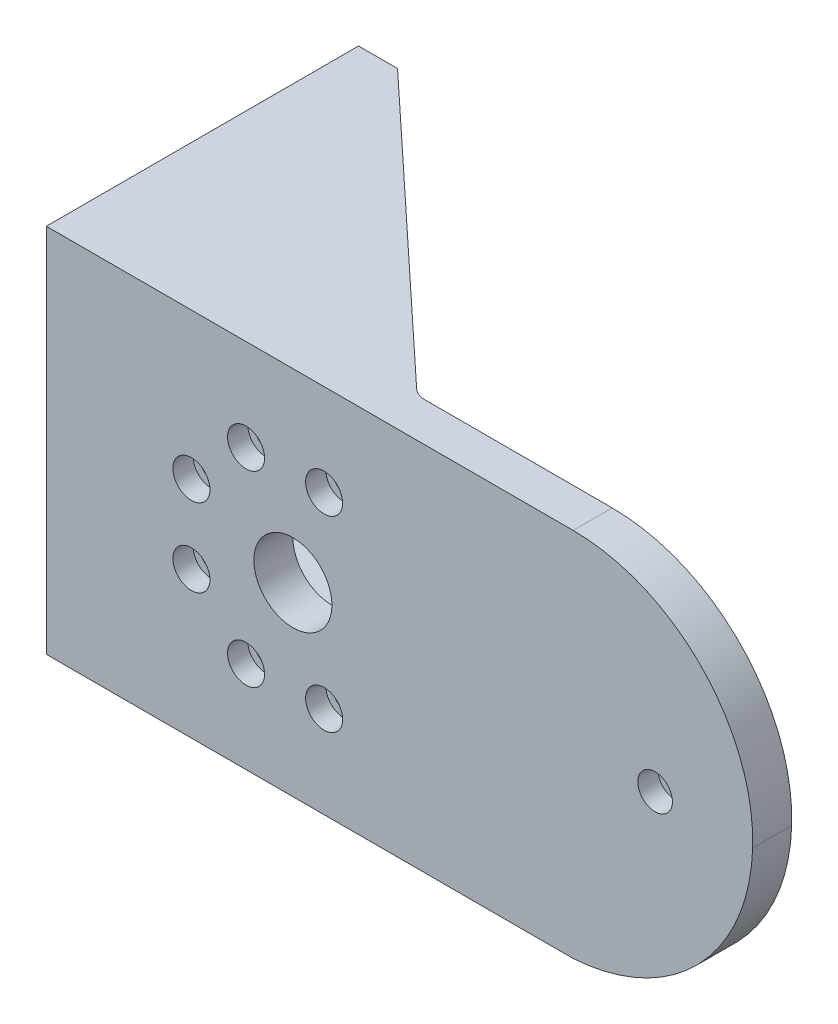
from build123d import *

# Parameters (mm, degrees)
SKETCH3_R           = 2.921
SKETCH3_R_2         = 10
SKETCH3_R_3         = 2.75
BOSS_EXTRUDE1_DEPTH = 10
SKETCH4_W           = 10
SKETCH4_H           = 95
BOSS_EXTRUDE2_DEPTH = 70
SKETCH8_R           = 10
SKETCH8_R_2         = 2.75
CUT_EXTRUDE2_DEPTH  = 43.8
BOSS_EXTRUDE3_DEPTH = 7.5
FILLET1_R           = 5
SKETCH14_R          = 4.75
SKETCH14_R_2        = 4.445
CUT_EXTRUDE4_DEPTH  = 5.2
SKETCH15_R          = 4.75
CUT_EXTRUDE5_DEPTH  = 5.3


with BuildPart() as part:
    # Sketch3 → Boss-Extrude1 (new body)
    with BuildSketch(Plane.XY):
        with BuildLine():
            Line((163.617133813, 80.05993294), (203.617133813, 80.05993294))
            ThreePointArc((203.617133813, 80.05993294), (236.678629544, 66.053697227), (249.617133813, 32.55993294))
            ThreePointArc((249.617133813, 32.55993294), (235.791661756, -0.074873068), (203.617133813, -14.94006706))
            Line((203.617133813, -14.94006706), (163.617133813, -14.94006706))
            Line((163.617133813, -14.94006706), (68.617133813, -14.94006706))
            Line((68.617133813, -14.94006706), (68.617133813, 80.05993294))
            Line((68.617133813, 80.05993294), (163.617133813, 80.05993294))
        make_face()
        with Locations((224.617133813, 32.55993294)):
            Circle(SKETCH3_R, mode=Mode.SUBTRACT)
        with Locations((131.802603987, 32.55993294)):
            Circle(SKETCH3_R_2, mode=Mode.SUBTRACT)
        with Locations((139.802603987, 8.55993294)):
            Circle(SKETCH3_R_3, mode=Mode.SUBTRACT)
        with Locations((119.802603987, 8.55993294)):
            Circle(SKETCH3_R_3, mode=Mode.SUBTRACT)
        with Locations((105.802603987, 22.55993294)):
            Circle(SKETCH3_R_3, mode=Mode.SUBTRACT)
        with Locations((105.802603987, 42.55993294)):
            Circle(SKETCH3_R_3, mode=Mode.SUBTRACT)
        with Locations((119.802603987, 56.55993294)):
            Circle(SKETCH3_R_3, mode=Mode.SUBTRACT)
        with Locations((139.802603987, 56.55993294)):
            Circle(SKETCH3_R_3, mode=Mode.SUBTRACT)
    extrude(amount=BOSS_EXTRUDE1_DEPTH)

    # Sketch4 → Boss-Extrude2 (add)
    with BuildSketch(Plane(origin=(0, 0, 0), x_dir=(-1, 0, 0), z_dir=(0, 0, -1))):
        with Locations((-73.617133813, 32.55993294)):
            Rectangle(SKETCH4_W, SKETCH4_H)
    extrude(amount=BOSS_EXTRUDE2_DEPTH)

    # Sketch8 → Cut-Extrude2 (cut)
    with BuildSketch(Plane.ZY.offset(-68.617133813)):
        with Locations((-40, 32.55993294)):
            Circle(SKETCH8_R)
        with Locations((-56.167891819, 25.862972874)):
            Circle(SKETCH8_R_2)
        with Locations((-56.167891819, 39.256893006)):
            Circle(SKETCH8_R_2)
        with Locations((-46.696960066, 48.727824759)):
            Circle(SKETCH8_R_2)
        with Locations((-33.303039934, 48.727824759)):
            Circle(SKETCH8_R_2)
        with Locations((-23.832108181, 39.256893006)):
            Circle(SKETCH8_R_2)
        with Locations((-23.832108181, 25.862972874)):
            Circle(SKETCH8_R_2)
        with Locations((-33.303039934, 16.392041121)):
            Circle(SKETCH8_R_2)
        with Locations((-46.696960066, 16.392041121)):
            Circle(SKETCH8_R_2)
    extrude(amount=-CUT_EXTRUDE2_DEPTH, mode=Mode.SUBTRACT)

    # Sketch9 → Boss-Extrude3 (add)
    with BuildSketch(Plane.XZ.offset(14.94006706)):
        Polygon((78.617133813, -70), (153.617133813, 0), (78.617133813, 0), align=None)
    boss_extrude3 = extrude(amount=-BOSS_EXTRUDE3_DEPTH)

    # Mirror1: Boss-Extrude3 across plane
    add(boss_extrude3.mirror(Plane(origin=(0, 32.55993294, 0), x_dir=(0, 0, 1), z_dir=(0, -1, 0))))

    # Fillet1
    fillet1_edges = [part.edges().sort_by_distance(p)[0] for p in [
        (153.617133813, -11.19006706, 0),
        (153.617133813, 76.30993294, 0),
    ]]
    fillet(fillet1_edges, radius=FILLET1_R)

    # Sketch14 → Cut-Extrude4 (cut)
    with BuildSketch(Plane.XY.offset(10)):
        with Locations((119.802603987, 56.55993294)):
            Circle(SKETCH14_R)
        with Locations((139.802603987, 56.55993294)):
            Circle(SKETCH14_R)
        with Locations((105.802603987, 42.55993294)):
            Circle(SKETCH14_R)
        with Locations((119.802603987, 8.55993294)):
            Circle(SKETCH14_R)
        with Locations((139.802603987, 8.55993294)):
            Circle(SKETCH14_R)
        with Locations((105.802603987, 22.55993294)):
            Circle(SKETCH14_R)
        with Locations((224.617133813, 32.55993294)):
            Circle(SKETCH14_R_2)
    extrude(amount=-CUT_EXTRUDE4_DEPTH, mode=Mode.SUBTRACT)

    # Sketch15 → Cut-Extrude5 (cut)
    with BuildSketch(Plane(origin=(78.617133813, 0, 0), x_dir=(0, 0, -1), z_dir=(1, 0, 0))):
        with Locations((23.832108181, 39.256893006)):
            Circle(SKETCH15_R)
        with Locations((33.303039934, 48.727824759)):
            Circle(SKETCH15_R)
        with Locations((46.696960066, 48.727824759)):
            Circle(SKETCH15_R)
        with Locations((56.167891819, 39.256893006)):
            Circle(SKETCH15_R)
        with Locations((56.167891819, 25.862972874)):
            Circle(SKETCH15_R)
        with Locations((46.696960066, 16.392041121)):
            Circle(SKETCH15_R)
        with Locations((33.303039934, 16.392041121)):
            Circle(SKETCH15_R)
        with Locations((23.832108181, 25.862972874)):
            Circle(SKETCH15_R)
    extrude(amount=-CUT_EXTRUDE5_DEPTH, mode=Mode.SUBTRACT)


solid = part.part
